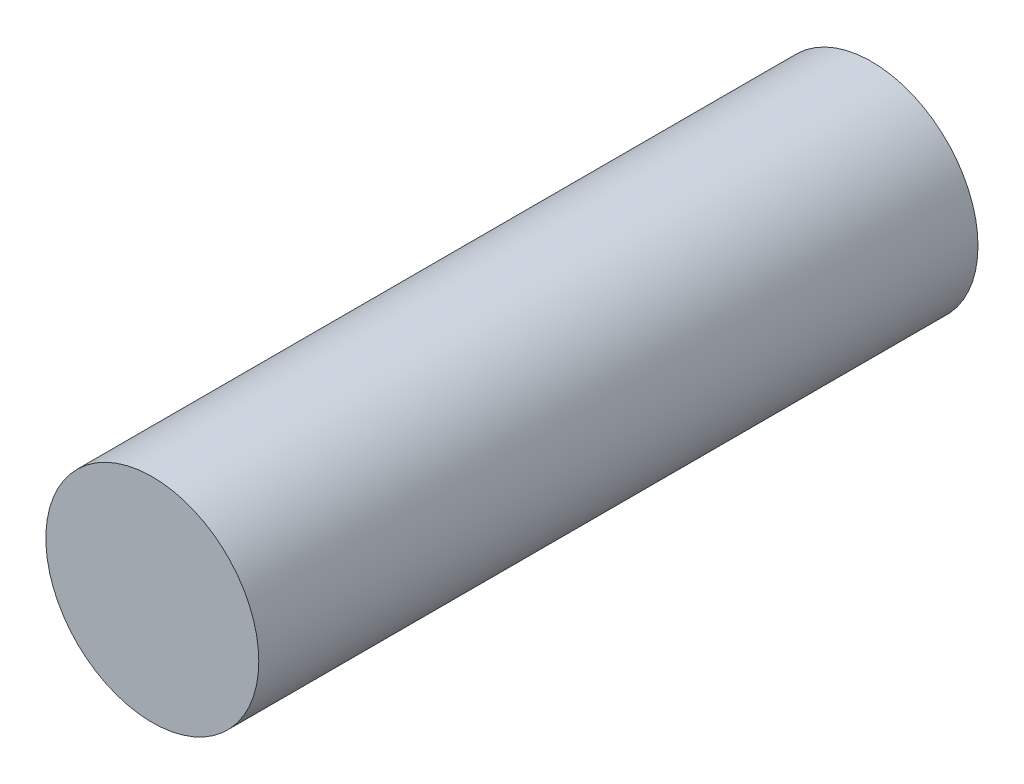
from build123d import *

# Parameters (mm, degrees)
SKETCH1_R           = 4.7752
BOSS_EXTRUDE1_DEPTH = 32.258


with BuildPart() as part:
    # Sketch1 → Boss-Extrude1 (new body)
    with BuildSketch(Plane.XY):
        Circle(SKETCH1_R)
    extrude(amount=BOSS_EXTRUDE1_DEPTH)


solid = part.part
